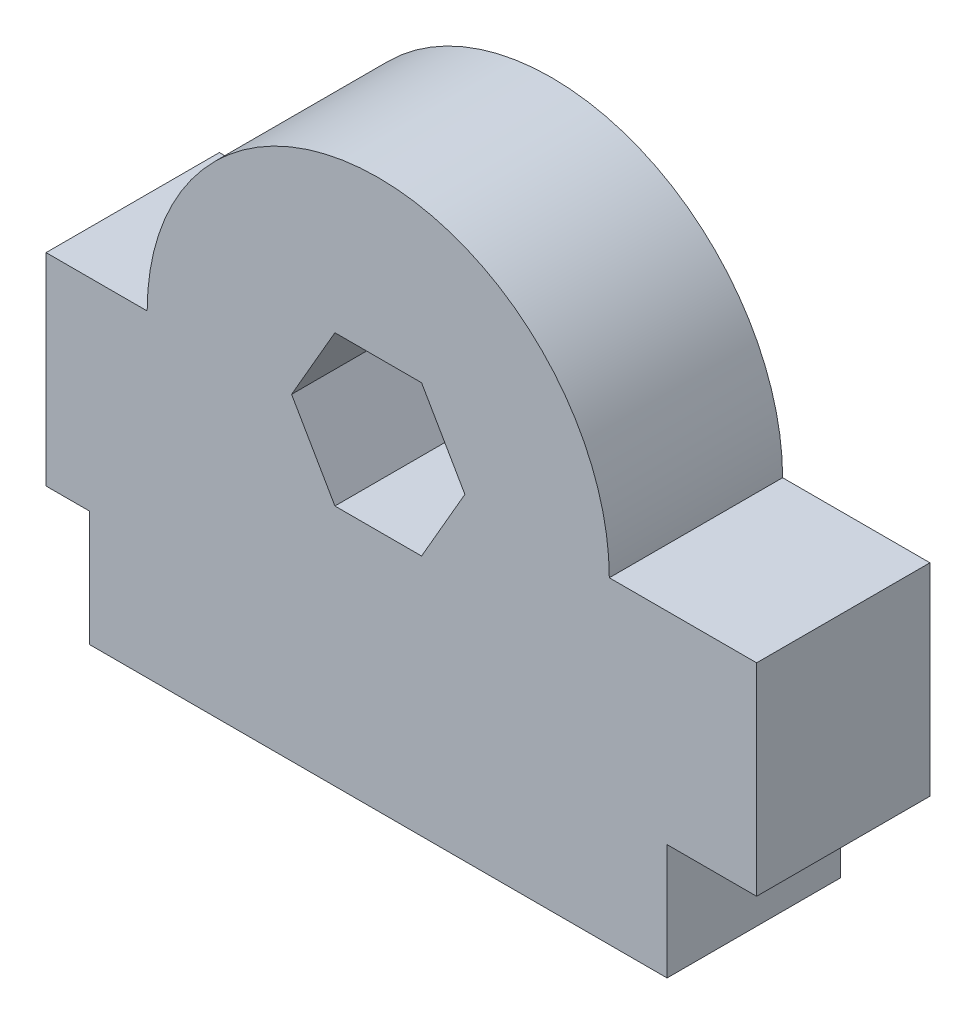
from build123d import *

# Parameters (mm, degrees)
BOSS_EXTRUDE1_DEPTH = 6


with BuildPart() as part:
    # Sketch1 → Boss-Extrude1 (new body)
    with BuildSketch(Plane.XY):
        with BuildLine():
            Line((0, 0), (20, 0))
            Line((20, 0), (20, 4))
            Line((20, 4), (23.1, 4))
            Line((23.1, 4), (23.1, 11))
            Line((23.1, 11), (18, 11))
            ThreePointArc((18, 11), (10, 19), (2, 11))
            Line((2, 11), (-1.5, 11))
            Line((-1.5, 11), (-1.5, 4))
            Line((-1.5, 4), (0, 4))
            Line((0, 4), (0, 0))
        make_face()
        Polygon((13, 11), (11.5, 13.598076211), (8.5, 13.598076211), (7, 11), (8.5, 8.401923789), (11.5, 8.401923789), align=None, mode=Mode.SUBTRACT)
    extrude(amount=BOSS_EXTRUDE1_DEPTH)


solid = part.part
